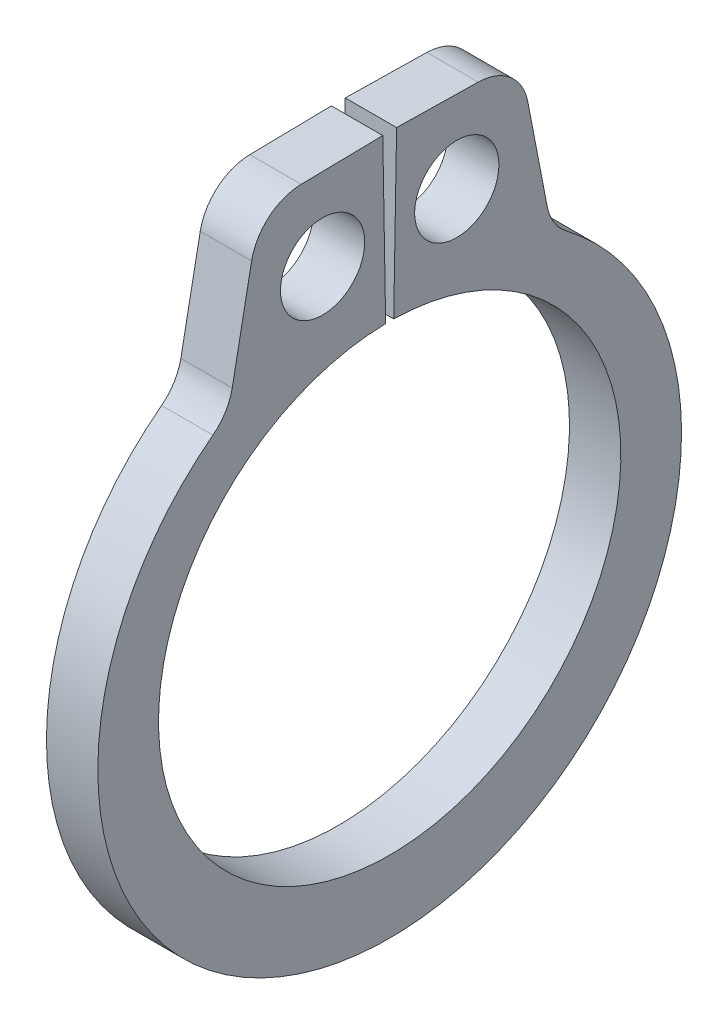
from build123d import *

# Parameters (mm, degrees)
SKETCH1_R      = 0.5207
EXTRUDE1_DEPTH = 0.3175
FILLET1_R      = 0.635


with BuildPart() as part:
    # Sketch1 → Extrude1 (new body, symmetric)
    with BuildSketch(Plane(origin=(0, 0, 0), x_dir=(0, 0, -1), z_dir=(1, 0, 0))):
        with BuildLine():
            Line((-0.049870251, 2.857064789), (-0.085333541, 4.888755305))
            Line((-0.085333541, 4.888755305), (-1.609101429, 4.862157838))
            Line((-1.609101429, 4.862157838), (-1.994422098, 2.867025767))
            ThreePointArc((-1.994422098, 2.867025767), (0, -3.7465), (1.994422098, 2.867025767))
            Line((1.994422098, 2.867025767), (1.609101429, 4.862157838))
            Line((1.609101429, 4.862157838), (0.085333541, 4.888755305))
            Line((0.085333541, 4.888755305), (0.049870251, 2.857064789))
            ThreePointArc((0.049870251, 2.857064789), (0, -2.8575), (-0.049870251, 2.857064789))
        make_face()
        with Locations((-0.82948584, 3.859611313)):
            Circle(SKETCH1_R, mode=Mode.SUBTRACT)
        with Locations((0.82948584, 3.859611313)):
            Circle(SKETCH1_R, mode=Mode.SUBTRACT)
    extrude(amount=EXTRUDE1_DEPTH, both=True)

    # Fillet1
    fillet1_edges = [part.edges().sort_by_distance(p)[0] for p in [
        (0, 4.862157838, -1.609101429),
        (0, 2.867025767, -1.994422098),
        (0, 2.867025767, 1.994422098),
        (0, 4.862157838, 1.609101429),
    ]]
    fillet(fillet1_edges, radius=FILLET1_R)


solid = part.part
